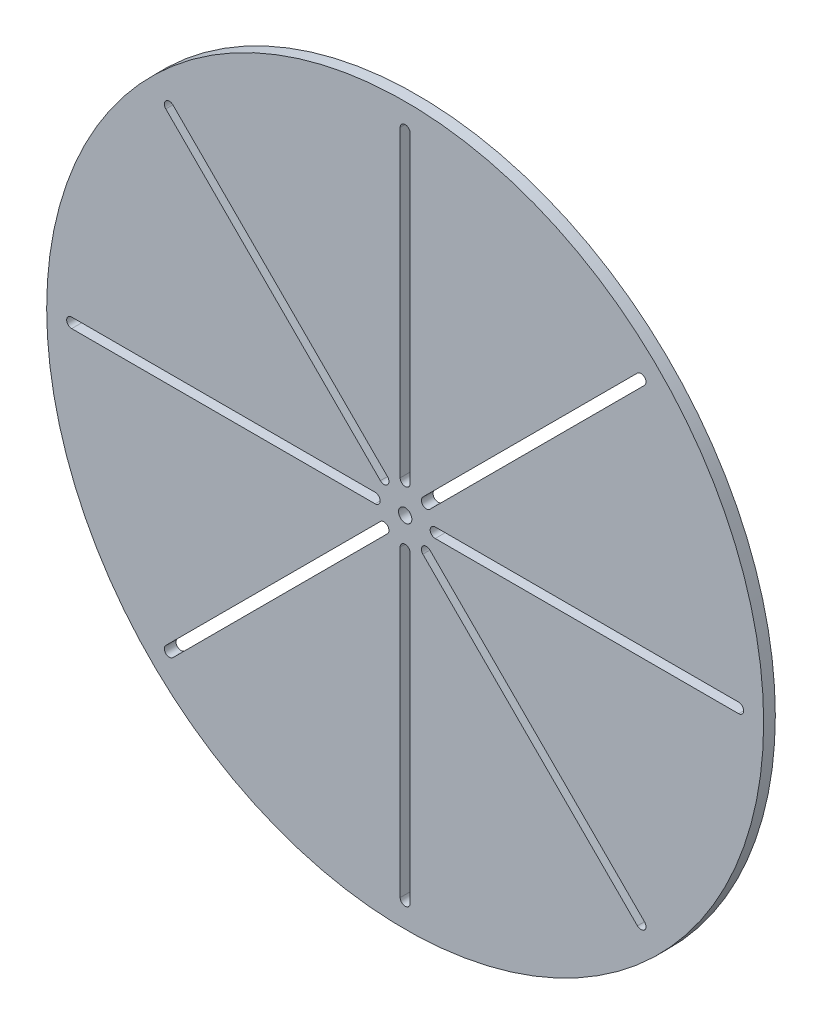
from build123d import *

# Parameters (mm, degrees)
SKETCH1_R           = 107.5
SKETCH1_R_2         = 2
BOSS_EXTRUDE1_DEPTH = 3.5


with BuildPart() as part:
    # Sketch1 → Boss-Extrude1 (new body)
    with BuildSketch(Plane.XY):
        Circle(SKETCH1_R)
        Circle(SKETCH1_R_2, mode=Mode.SUBTRACT)
        with BuildLine():
            Line((9, 1.5), (100, 1.5))
            ThreePointArc((100, 1.5), (101.5, 0), (100, -1.5))
            Line((100, -1.5), (9, -1.5))
            ThreePointArc((9, -1.5), (7.5, 0), (9, 1.5))
        make_face(mode=Mode.SUBTRACT)
        with BuildLine():
            Line((7.424621202, -5.303300859), (71.77133829, -69.650017947))
            ThreePointArc((71.77133829, -69.650017947), (71.77133829, -71.77133829), (69.650017947, -71.77133829))
            Line((69.650017947, -71.77133829), (5.303300859, -7.424621202))
            ThreePointArc((5.303300859, -7.424621202), (5.303300859, -5.303300859), (7.424621202, -5.303300859))
        make_face(mode=Mode.SUBTRACT)
        with BuildLine():
            Line((1.5, -9), (1.5, -100))
            ThreePointArc((1.5, -100), (0, -101.5), (-1.5, -100))
            Line((-1.5, -100), (-1.5, -9))
            ThreePointArc((-1.5, -9), (0, -7.5), (1.5, -9))
        make_face(mode=Mode.SUBTRACT)
        with BuildLine():
            Line((-5.303300859, -7.424621202), (-69.650017947, -71.77133829))
            ThreePointArc((-69.650017947, -71.77133829), (-71.77133829, -71.77133829), (-71.77133829, -69.650017947))
            Line((-71.77133829, -69.650017947), (-7.424621202, -5.303300859))
            ThreePointArc((-7.424621202, -5.303300859), (-5.303300859, -5.303300859), (-5.303300859, -7.424621202))
        make_face(mode=Mode.SUBTRACT)
        with BuildLine():
            Line((-9, -1.5), (-100, -1.5))
            ThreePointArc((-100, -1.5), (-101.5, 0), (-100, 1.5))
            Line((-100, 1.5), (-9, 1.5))
            ThreePointArc((-9, 1.5), (-7.5, 0), (-9, -1.5))
        make_face(mode=Mode.SUBTRACT)
        with BuildLine():
            Line((-7.424621202, 5.303300859), (-71.77133829, 69.650017947))
            ThreePointArc((-71.77133829, 69.650017947), (-71.77133829, 71.77133829), (-69.650017947, 71.77133829))
            Line((-69.650017947, 71.77133829), (-5.303300859, 7.424621202))
            ThreePointArc((-5.303300859, 7.424621202), (-5.303300859, 5.303300859), (-7.424621202, 5.303300859))
        make_face(mode=Mode.SUBTRACT)
        with BuildLine():
            Line((-1.5, 9), (-1.5, 100))
            ThreePointArc((-1.5, 100), (0, 101.5), (1.5, 100))
            Line((1.5, 100), (1.5, 9))
            ThreePointArc((1.5, 9), (0, 7.5), (-1.5, 9))
        make_face(mode=Mode.SUBTRACT)
        with BuildLine():
            Line((5.303300859, 7.424621202), (69.650017947, 71.77133829))
            ThreePointArc((69.650017947, 71.77133829), (71.77133829, 71.77133829), (71.77133829, 69.650017947))
            Line((71.77133829, 69.650017947), (7.424621202, 5.303300859))
            ThreePointArc((7.424621202, 5.303300859), (5.303300859, 5.303300859), (5.303300859, 7.424621202))
        make_face(mode=Mode.SUBTRACT)
    extrude(amount=BOSS_EXTRUDE1_DEPTH)


solid = part.part
